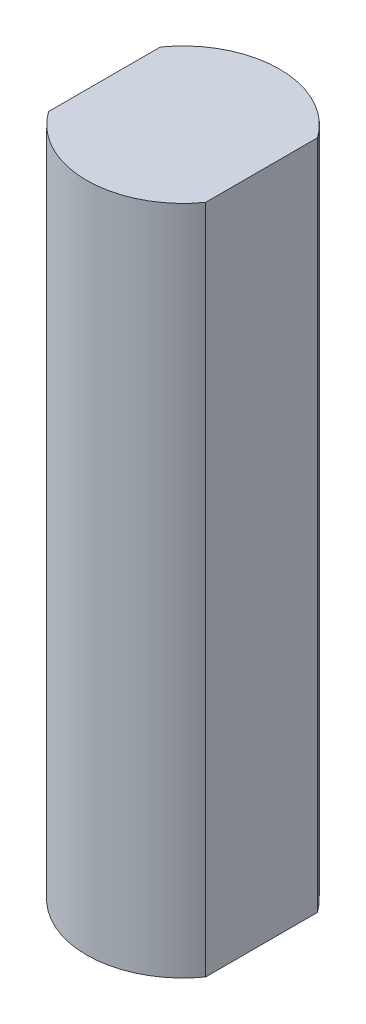
from build123d import *

# Parameters (mm, degrees)
SKETCH1_R           = 4.3815
BOSS_EXTRUDE1_DEPTH = 30.48
CUT_EXTRUDE1_DEPTH  = 48.26


with BuildPart() as part:
    # Sketch1 → Boss-Extrude1 (new body)
    with BuildSketch(Plane(origin=(0, 0, 0), x_dir=(1, 0, 0), z_dir=(0, 1, 0))):
        Circle(SKETCH1_R)
    extrude(amount=BOSS_EXTRUDE1_DEPTH)

    # Sketch2 → Cut-Extrude1 (cut)
    with BuildSketch(Plane(origin=(0, 30.48, 0), x_dir=(1, 0, 0), z_dir=(0, 1, 0))):
        with BuildLine():
            Line((-3.57014597, -2.54), (-3.57014597, 2.54))
            ThreePointArc((-3.57014597, 2.54), (-4.3815, 0), (-3.57014597, -2.54))
        make_face()
        with BuildLine():
            ThreePointArc((4.3815, 0), (4.173735546, 1.333219352), (3.57014597, 2.54))
            Line((3.57014597, 2.54), (3.57014597, -2.54))
            ThreePointArc((3.57014597, -2.54), (4.173735546, -1.333219352), (4.3815, 0))
        make_face()
    extrude(amount=-CUT_EXTRUDE1_DEPTH, mode=Mode.SUBTRACT)


solid = part.part
